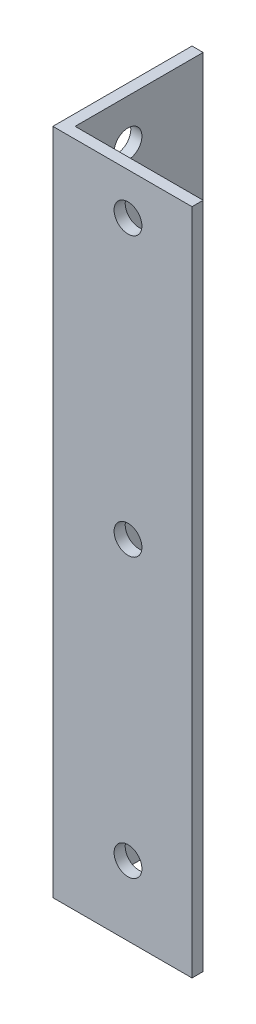
from build123d import *

# Parameters (mm, degrees)
EXTRUDE_1_DEPTH     = 240
SKETCH_2_R          = 5
CUT_EXTRUDE_1_DEPTH = 10
SKETCH_3_R          = 5
CUT_EXTRUDE_2_DEPTH = 10


with BuildPart() as part:
    # Эскиз1 → Вытянуть-Тонкостенный1 (new body)
    with BuildSketch(Plane(origin=(0, 0, 0), x_dir=(1, 0, 0), z_dir=(0, 1, 0))):
        Polygon((0, 50), (0, 0), (50, 0), (50, 4), (4, 4), (4, 50), align=None)
    extrude(amount=EXTRUDE_1_DEPTH)

    # Эскиз2 → Вырез-Вытянуть1 (cut)
    with BuildSketch(Plane.XY):
        with Locations((27, 225)):
            Circle(SKETCH_2_R)
        with Locations((27, 125)):
            Circle(SKETCH_2_R)
        with Locations((27, 25)):
            Circle(SKETCH_2_R)
    extrude(amount=-CUT_EXTRUDE_1_DEPTH, mode=Mode.SUBTRACT)

    # Эскиз3 → Вырез-Вытянуть2 (cut)
    with BuildSketch(Plane.ZY):
        with Locations((-23, 225)):
            Circle(SKETCH_3_R)
        with Locations((-23, 125)):
            Circle(SKETCH_3_R)
        with Locations((-23, 25)):
            Circle(SKETCH_3_R)
    extrude(amount=-CUT_EXTRUDE_2_DEPTH, mode=Mode.SUBTRACT)


solid = part.part
